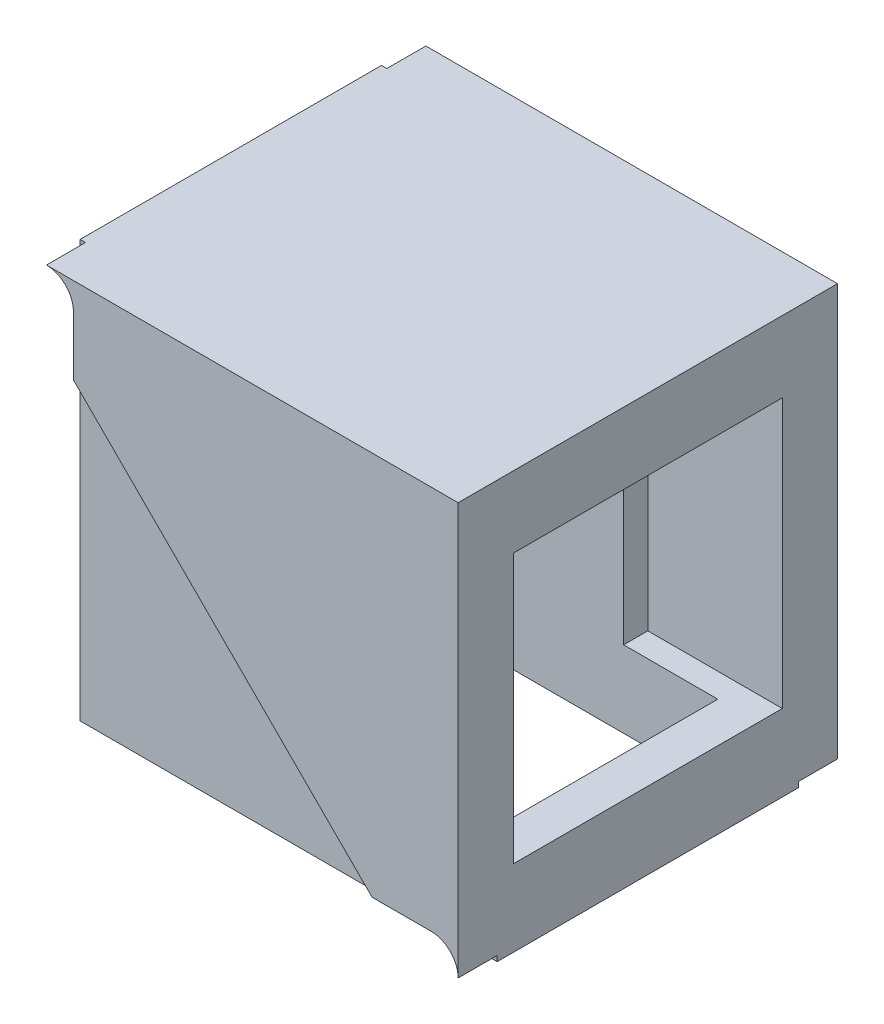
from build123d import *

# Parameters (mm, degrees)
SKETCH_5_W          = 31
SKETCH_5_H          = 31
EXTRUDE_1_DEPTH     = 3
SKETCH_6_W          = 31
SKETCH_6_H          = 31
EXTRUDE_2_DEPTH     = 3
EXTRUDE_3_DEPTH     = 2.9
EXTRUDE_4_DEPTH     = 2.9
EXTRUDE_5_DEPTH     = 16.4
SKETCH_10_W         = 20
SKETCH_10_H         = 20
CUT_EXTRUDE_1_DEPTH = 10


with BuildPart() as part:
    # 草图5 → 凸台-拉伸1 (new body)
    with BuildSketch(Plane(origin=(835, 815, -2.8), x_dir=(-1, 0, 0), z_dir=(0, 0, 1))):
        with Locations((815.5, 795.5)):
            Rectangle(SKETCH_5_W, SKETCH_5_H)
    extrude(amount=-EXTRUDE_1_DEPTH)

    # 草图8 → 凸台-拉伸4 (add)
    with BuildSketch(Plane.XY.offset(-2.8)):
        with BuildLine():
            Line((6.4, 33), (6.4, 28.6))
            Line((6.4, 28.6), (28.6, 6.4))
            Line((28.6, 6.4), (33, 6.4))
            ThreePointArc((33, 6.4), (34.414213562, 5.814213562), (35, 4.4))
            Line((35, 4.4), (35, 35))
            Line((35, 35), (4.4, 35))
            ThreePointArc((4.4, 35), (5.814213562, 34.414213562), (6.4, 33))
        make_face()
    extrude(amount=EXTRUDE_4_DEPTH)



with BuildPart() as body_2:
    # 草图6 → 凸台-拉伸2 (new body)
    with BuildSketch(Plane(origin=(835, 815, -25.2), x_dir=(-1, 0, 0), z_dir=(0, 0, 1))):
        with Locations((815.5, 795.5)):
            Rectangle(SKETCH_6_W, SKETCH_6_H)
    extrude(amount=EXTRUDE_2_DEPTH)

    # 草图7 → 凸台-拉伸3 (add)
    with BuildSketch(Plane(origin=(0, 0, -25.2), x_dir=(-1, 0, 0), z_dir=(0, 0, -1))):
        with BuildLine():
            Line((-6.4, 28.6), (-28.6, 6.4))
            Line((-28.6, 6.4), (-33, 6.4))
            ThreePointArc((-33, 6.4), (-34.414213562, 5.814213562), (-35, 4.4))
            Line((-35, 4.4), (-35, 35))
            Line((-35, 35), (-4.4, 35))
            ThreePointArc((-4.4, 35), (-5.814213562, 34.414213562), (-6.4, 33))
            Line((-6.4, 33), (-6.4, 28.6))
        make_face()
    extrude(amount=EXTRUDE_3_DEPTH)


with BuildPart() as part_1:
    add(part.part)

    add(body_2.part)  # 凸台-拉伸5 merges body 2
    # 草图9 → 凸台-拉伸5 (add)
    with BuildSketch(Plane(origin=(0, 0, -5.8), x_dir=(-1, 0, 0), z_dir=(0, 0, -1))):
        Polygon((-35, 4), (-32, 4), (-32, 32), (-4, 32), (-4, 35), (-35, 35), align=None)
    extrude(amount=EXTRUDE_5_DEPTH)

    # 草图10 → 切除-拉伸1 (cut)
    with BuildSketch(Plane(origin=(35, 0, 0), x_dir=(0, 0, -1), z_dir=(1, 0, 0))):
        with Locations((14, 19.7)):
            Rectangle(SKETCH_10_W, SKETCH_10_H)
    extrude(amount=-CUT_EXTRUDE_1_DEPTH, mode=Mode.SUBTRACT)


solid = part_1.part
